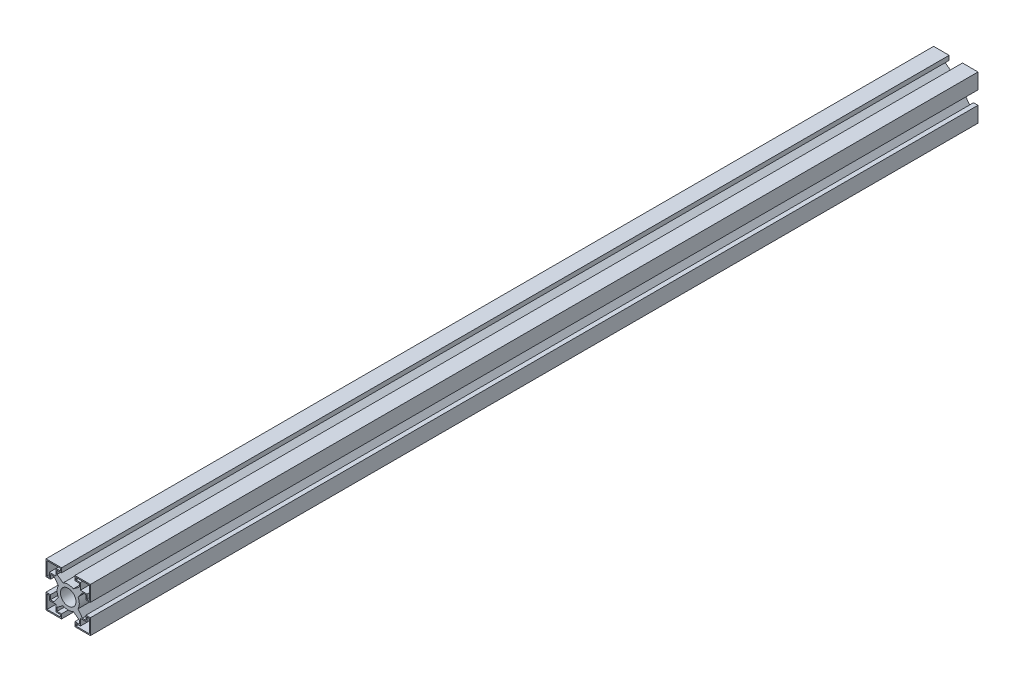
from build123d import *

# Parameters (mm, degrees)
ESQUISSE1_R        = 1.75
BOSS_EXTRU_1_DEPTH = 200


with BuildPart() as part:
    # Esquisse1 → Boss.-Extru.1 (new body)
    with BuildSketch(Plane.XY):
        with BuildLine():
            Line((-1.5, 5), (-5, 5))
            Line((-5, 5), (-5, 1.5))
            Line((-5, 1.5), (-4, 1.5))
            Line((-4, 1.5), (-4, 2.5))
            Line((-4, 2.5), (-3.207106781, 2.5))
            Line((-3.207106781, 2.5), (-2.216672281, 1.15601211))
            ThreePointArc((-2.216672281, 1.15601211), (-2.5, 0), (-2.216672281, -1.15601211))
            Line((-2.216672281, -1.15601211), (-3.207106781, -2.5))
            Line((-3.207106781, -2.5), (-4, -2.5))
            Line((-4, -2.5), (-4, -1.5))
            Line((-4, -1.5), (-5, -1.5))
            Line((-5, -1.5), (-5, -5))
            Line((-5, -5), (-1.5, -5))
            Line((-1.5, -5), (-1.5, -4))
            Line((-1.5, -4), (-2.5, -4))
            Line((-2.5, -4), (-2.5, -3.207106781))
            Line((-2.5, -3.207106781), (-1.15601211, -2.216672281))
            ThreePointArc((-1.15601211, -2.216672281), (0, -2.5), (1.15601211, -2.216672281))
            Line((1.15601211, -2.216672281), (2.5, -3.207106781))
            Line((2.5, -3.207106781), (2.5, -4))
            Line((2.5, -4), (1.5, -4))
            Line((1.5, -4), (1.5, -5))
            Line((1.5, -5), (5, -5))
            Line((5, -5), (5, -1.5))
            Line((5, -1.5), (4, -1.5))
            Line((4, -1.5), (4, -2.5))
            Line((4, -2.5), (3.207106781, -2.5))
            Line((3.207106781, -2.5), (2.216672281, -1.15601211))
            ThreePointArc((2.216672281, -1.15601211), (2.5, 0), (2.216672281, 1.15601211))
            Line((2.216672281, 1.15601211), (3.207106781, 2.5))
            Line((3.207106781, 2.5), (4, 2.5))
            Line((4, 2.5), (4, 1.5))
            Line((4, 1.5), (5, 1.5))
            Line((5, 1.5), (5, 5))
            Line((5, 5), (1.5, 5))
            Line((1.5, 5), (1.5, 4))
            Line((1.5, 4), (2.5, 4))
            Line((2.5, 4), (2.5, 3.207106781))
            Line((2.5, 3.207106781), (1.15601211, 2.216672281))
            ThreePointArc((1.15601211, 2.216672281), (0, 2.5), (-1.15601211, 2.216672281))
            Line((-1.15601211, 2.216672281), (-2.5, 3.207106781))
            Line((-2.5, 3.207106781), (-2.5, 4))
            Line((-2.5, 4), (-1.5, 4))
            Line((-1.5, 4), (-1.5, 5))
        make_face()
        Polygon((-4.75, 1.75), (-4.75, 4.75), (-1.75, 4.75), (-1.75, 4.25), (-2.75, 4.25), (-2.75, 2.75), (-4.25, 2.75), (-4.25, 1.75), align=None, mode=Mode.SUBTRACT)
        Circle(ESQUISSE1_R, mode=Mode.SUBTRACT)
        Polygon((-4.75, -4.75), (-4.75, -1.75), (-4.25, -1.75), (-4.25, -2.75), (-2.75, -2.75), (-2.75, -4.25), (-1.75, -4.25), (-1.75, -4.75), align=None, mode=Mode.SUBTRACT)
        Polygon((4.75, 4.75), (4.75, 1.75), (4.25, 1.75), (4.25, 2.75), (2.75, 2.75), (2.75, 4.25), (1.75, 4.25), (1.75, 4.75), align=None, mode=Mode.SUBTRACT)
        Polygon((4.75, -4.75), (1.75, -4.75), (1.75, -4.25), (2.75, -4.25), (2.75, -2.75), (4.25, -2.75), (4.25, -1.75), (4.75, -1.75), align=None, mode=Mode.SUBTRACT)
    extrude(amount=BOSS_EXTRU_1_DEPTH)


solid = part.part
